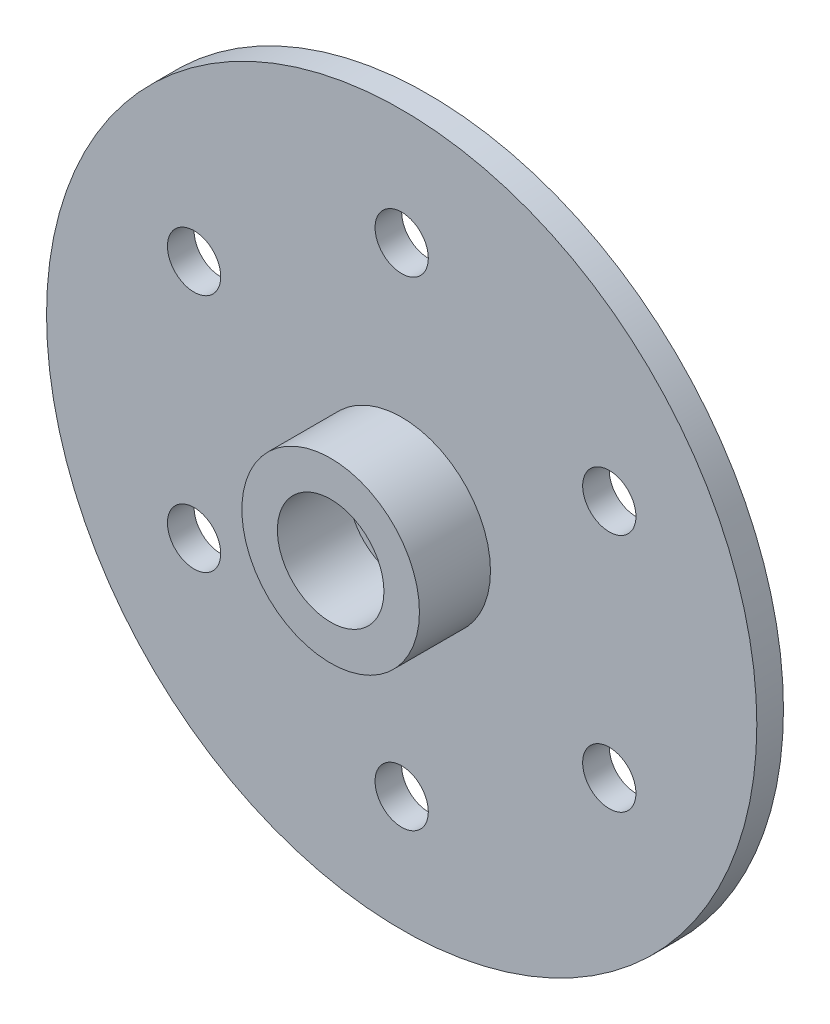
from build123d import *

# Parameters (mm, degrees)
SKETCH1_R           = 20
SKETCH1_R_2         = 1.5
SKETCH1_R_3         = 1
BOSS_EXTRUDE1_DEPTH = 1.5
SKETCH2_R           = 5
SKETCH2_R_2         = 3
BOSS_EXTRUDE2_DEPTH = 4


with BuildPart() as part:
    # Sketch1 → Boss-Extrude1 (new body)
    with BuildSketch(Plane.XY):
        with Locations((-34.248726775, 70.794412983)):
            Circle(SKETCH1_R)
        with Locations((-45.940069726, 77.544412983)):
            Circle(SKETCH1_R_2, mode=Mode.SUBTRACT)
        with Locations((-34.248726775, 84.294412983)):
            Circle(SKETCH1_R_2, mode=Mode.SUBTRACT)
        with Locations((-22.557383823, 77.544412983)):
            Circle(SKETCH1_R_2, mode=Mode.SUBTRACT)
        with Locations((-22.557383823, 64.044412983)):
            Circle(SKETCH1_R_2, mode=Mode.SUBTRACT)
        with Locations((-34.248726775, 57.294412983)):
            Circle(SKETCH1_R_2, mode=Mode.SUBTRACT)
        with Locations((-45.940069726, 64.044412983)):
            Circle(SKETCH1_R_2, mode=Mode.SUBTRACT)
        with Locations((-34.248726775, 70.794412983)):
            Circle(SKETCH1_R_3, mode=Mode.SUBTRACT)
    extrude(amount=BOSS_EXTRUDE1_DEPTH)

    # Sketch2 → Boss-Extrude2 (add)
    with BuildSketch(Plane.XY.offset(1.5)):
        with Locations((-34.248726775, 70.794412983)):
            Circle(SKETCH2_R)
        with Locations((-34.248726775, 70.794412983)):
            Circle(SKETCH2_R_2, mode=Mode.SUBTRACT)
    extrude(amount=BOSS_EXTRUDE2_DEPTH)


solid = part.part
